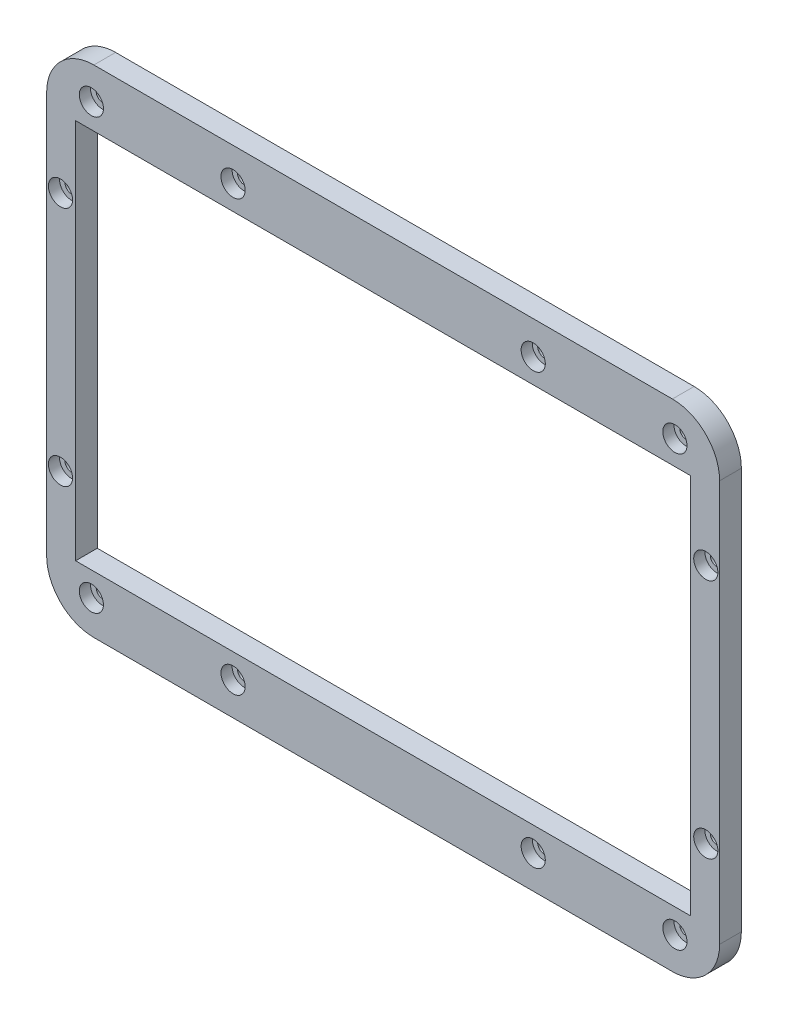
from build123d import *

# Parameters (mm, degrees)
SKETCH1_W                                      = 180.975
SKETCH1_H                                      = 133.35
SKETCH1_W_2                                    = 165.408
SKETCH1_H_2                                    = 102.508
BOSS_EXTRUDE1_DEPTH                            = 5.842
FILLET2_R                                      = 12.7
CBORE_FOR_M3_SHCS1_D                           = 3.4
CBORE_FOR_M3_SHCS1_DEPTH                       = 4.064
CBORE_FOR_M3_SHCS1_CBORE_D                     = 6.5
CBORE_FOR_M3_SHCS1_CBORE_DEPTH                 = 3
CBORE_FOR_M3_SHCS1_TIP                         = 1.021463052
CBORE_FOR_M3_SHCS2_D                           = 3.6
CBORE_FOR_M3_SHCS2_DEPTH                       = 5.842
CBORE_FOR_M3_SHCS2_CBORE_D                     = 6.5
CBORE_FOR_M3_SHCS2_CBORE_DEPTH                 = 3
MIRROR1_AT_THE_SECOND_PLANE_COPY_1_D           = 3.6
MIRROR1_AT_THE_SECOND_PLANE_COPY_1_DEPTH       = 5.842
MIRROR1_AT_THE_SECOND_PLANE_COPY_1_CBORE_D     = 6.5
MIRROR1_AT_THE_SECOND_PLANE_COPY_1_CBORE_DEPTH = 3


with BuildPart() as part:
    # Sketch1 → Boss-Extrude1 (new body)
    with BuildSketch(Plane.XY):
        with Locations((78.461, -0.01)):
            Rectangle(SKETCH1_W, SKETCH1_H)
        with Locations((78.461, -0.01)):
            Rectangle(SKETCH1_W_2, SKETCH1_H_2, mode=Mode.SUBTRACT)
    extrude(amount=BOSS_EXTRUDE1_DEPTH)

    # Fillet2
    fillet2_edges = [part.edges().sort_by_distance(p)[0] for p in [
        (168.9485, -66.685, 2.921),
        (168.9485, 66.665, 2.921),
        (-12.0265, 66.665, 2.921),
        (-12.0265, -66.685, 2.921),
    ]]
    fillet(fillet2_edges, radius=FILLET2_R)

    # CBORE for M3 SHCS1
    with Locations(Plane.XY.offset(5.842)):
        with Locations((0, 57.785), (156.922, 57.785), (156.922, -57.785), (0, -57.785)):
            CounterBoreHole(CBORE_FOR_M3_SHCS1_D / 2, CBORE_FOR_M3_SHCS1_CBORE_D / 2, CBORE_FOR_M3_SHCS1_CBORE_DEPTH, depth=CBORE_FOR_M3_SHCS1_DEPTH)
            with Locations((0, 0, -(CBORE_FOR_M3_SHCS1_DEPTH + CBORE_FOR_M3_SHCS1_TIP / 2))):  # 118° drill point
                Cone(0, CBORE_FOR_M3_SHCS1_D / 2, CBORE_FOR_M3_SHCS1_TIP, mode=Mode.SUBTRACT)

    # CBORE for M3 SHCS2
    with Locations(Plane.XY.offset(5.842)):
        with Locations((38.1, 57.785), (-8.306756121, 32.385)):
            cbore_for_m3_shcs2 = CounterBoreHole(CBORE_FOR_M3_SHCS2_D / 2, CBORE_FOR_M3_SHCS2_CBORE_D / 2, CBORE_FOR_M3_SHCS2_CBORE_DEPTH, depth=CBORE_FOR_M3_SHCS2_DEPTH)

    # Mirror1: CBORE for M3 SHCS2 across plane
    add(cbore_for_m3_shcs2.mirror(Plane(origin=(0, -0.01, 0), x_dir=(0, 0, 1), z_dir=(0, -1, 0))), mode=Mode.SUBTRACT)

    # Mirror1 at the second plane: CBORE for M3 SHCS2 across plane
    add(cbore_for_m3_shcs2.mirror(Plane(origin=(78.461, 0, 0), x_dir=(0, 0, 1), z_dir=(1, 0, 0))), mode=Mode.SUBTRACT)

    # Mirror1 at the second plane copy 1
    with Locations(Plane(origin=(156.922, -0.02, 5.842), x_dir=(-1, 0, 0), z_dir=(0, 0, 1))):
        with Locations((38.1, 57.785), (-8.306756121, 32.385)):
            CounterBoreHole(MIRROR1_AT_THE_SECOND_PLANE_COPY_1_D / 2, MIRROR1_AT_THE_SECOND_PLANE_COPY_1_CBORE_D / 2, MIRROR1_AT_THE_SECOND_PLANE_COPY_1_CBORE_DEPTH, depth=MIRROR1_AT_THE_SECOND_PLANE_COPY_1_DEPTH)


solid = part.part
